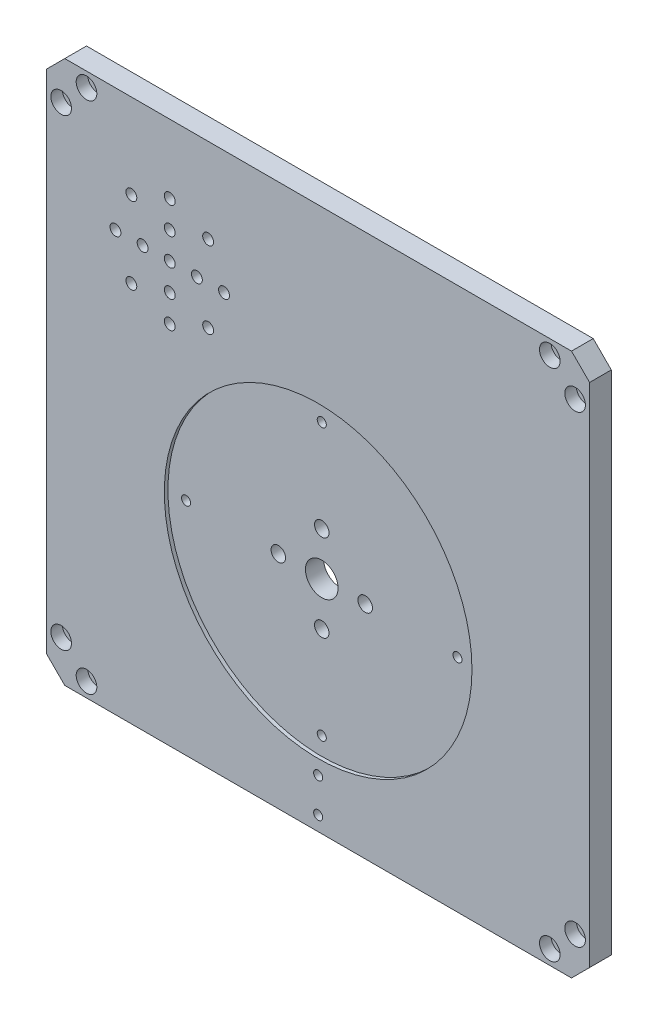
from build123d import *

# Parameters (mm, degrees)
SKETCH_1_W             = 150
SKETCH_1_H             = 150
EXTRUDE_1_DEPTH        = 6
SKETCH_2_R             = 42.5
CUT_EXTRUDE_1_DEPTH    = 1
CHAMFER_1_SIZE         = 5
SKETCH_4_R             = 1.5
CUT_EXTRUDE_3_DEPTH    = 10
SKETCH_5_R             = 2.85
CUT_EXTRUDE_4_DEPTH    = 3.2
SKETCH_6_R             = 1.5
CUT_EXTRUDE_5_DEPTH    = 10
SKETCH_7_R             = 2.85
CUT_EXTRUDE_6_DEPTH    = 3.2
SKETCH_8_R             = 4.5
CUT_EXTRUDE_7_DEPTH    = 10
SKETCH_9_R             = 2
CUT_EXTRUDE_8_DEPTH    = 10
SKETCH_10_R            = 1
CUT_EXTRUDE_9_DEPTH    = 10
HOLE_WIZARD_M3_1_D     = 2.5
HOLE_WIZARD_M3_1_DEPTH = 7.5
HOLE_WIZARD_M3_1_TIP   = 0.751075774
SKETCH_15_R            = 25.5
CUT_EXTRUDE_12_DEPTH   = 3
SKETCH_16_R            = 1.5
CUT_EXTRUDE_13_DEPTH   = 3
SKETCH_17_R            = 1
CUT_EXTRUDE_14_DEPTH   = 10
HOLE_WIZARD_M3_2_D     = 2.5
HOLE_WIZARD_M3_2_DEPTH = 7.5
HOLE_WIZARD_M3_2_TIP   = 0.751075774


with BuildPart() as part:
    # 草图1 → 凸台-拉伸1 (new body)
    with BuildSketch(Plane.XY):
        Rectangle(SKETCH_1_W, SKETCH_1_H)
    extrude(amount=EXTRUDE_1_DEPTH)

    # 草图2 → 切除-拉伸1 (cut)
    with BuildSketch(Plane.XY.offset(6)):
        with Locations((0, -15)):
            Circle(SKETCH_2_R)
    extrude(amount=-CUT_EXTRUDE_1_DEPTH, mode=Mode.SUBTRACT)

    # 倒角1
    chamfer_1_edges = [part.edges().sort_by_distance(p)[0] for p in [
        (-75, 75, 3),
        (75, 75, 3),
        (75, -75, 3),
        (-75, -75, 3),
    ]]
    chamfer(chamfer_1_edges, length=CHAMFER_1_SIZE)

    # 草图4 → 切除-拉伸3 (cut)
    with BuildSketch(Plane.XY.offset(6)):
        with Locations((64, 71)):
            Circle(SKETCH_4_R)
        with Locations((71, 64)):
            Circle(SKETCH_4_R)
    cut_extrude_3 = extrude(amount=-CUT_EXTRUDE_3_DEPTH, mode=Mode.SUBTRACT)

    # 草图5 → 切除-拉伸4 (cut)
    with BuildSketch(Plane.XY.offset(6)):
        with Locations((64, 71)):
            Circle(SKETCH_5_R)
        with Locations((71, 64)):
            Circle(SKETCH_5_R)
    cut_extrude_4 = extrude(amount=-CUT_EXTRUDE_4_DEPTH, mode=Mode.SUBTRACT)

    # 草图6 → 切除-拉伸5 (cut)
    with BuildSketch(Plane.XY.offset(6)):
        with Locations((-64, 71)):
            Circle(SKETCH_6_R)
        with Locations((-71, 64)):
            Circle(SKETCH_6_R)
    cut_extrude_5 = extrude(amount=-CUT_EXTRUDE_5_DEPTH, mode=Mode.SUBTRACT)

    # 草图7 → 切除-拉伸6 (cut)
    with BuildSketch(Plane.XY.offset(6)):
        with Locations((-64, 71)):
            Circle(SKETCH_7_R)
        with Locations((-71, 64)):
            Circle(SKETCH_7_R)
    cut_extrude_6 = extrude(amount=-CUT_EXTRUDE_6_DEPTH, mode=Mode.SUBTRACT)

    # 镜向1: 切除-拉伸3, 切除-拉伸4, 切除-拉伸5, 切除-拉伸6 across plane
    add(cut_extrude_3.mirror(Plane.ZX), mode=Mode.SUBTRACT)
    add(cut_extrude_4.mirror(Plane.ZX), mode=Mode.SUBTRACT)
    add(cut_extrude_5.mirror(Plane.ZX), mode=Mode.SUBTRACT)
    add(cut_extrude_6.mirror(Plane.ZX), mode=Mode.SUBTRACT)

    # 草图8 → 切除-拉伸7 (cut)
    with BuildSketch(Plane.XY.offset(5)):
        with Locations((0, -15)):
            Circle(SKETCH_8_R)
    extrude(amount=-CUT_EXTRUDE_7_DEPTH, mode=Mode.SUBTRACT)

    # 草图9 → 切除-拉伸8 (cut)
    with BuildSketch(Plane.XY.offset(5)):
        with Locations((-12, -15)):
            Circle(SKETCH_9_R)
        with Locations((12, -15)):
            Circle(SKETCH_9_R)
        with Locations((0, -27)):
            Circle(SKETCH_9_R)
        with Locations((0, -3)):
            Circle(SKETCH_9_R)
    extrude(amount=-CUT_EXTRUDE_8_DEPTH, mode=Mode.SUBTRACT)

    # 草图10 → 切除-拉伸9 (cut)
    with BuildSketch(Plane.XY.offset(5)):
        with Locations((0, 22.5)):
            Circle(SKETCH_10_R)
        with Locations((37.5, -15)):
            Circle(SKETCH_10_R)
        with Locations((0, -52.5)):
            Circle(SKETCH_10_R)
        with Locations((-37.5, -15)):
            Circle(SKETCH_10_R)
    extrude(amount=-CUT_EXTRUDE_9_DEPTH, mode=Mode.SUBTRACT)

    # M3 螺纹孔1
    with Locations(Plane.XY.offset(5)):
        with Locations((0, 22.5), (-37.5, -15), (0, -52.5), (37.5, -15)):
            Hole(HOLE_WIZARD_M3_1_D / 2, depth=HOLE_WIZARD_M3_1_DEPTH)
            with Locations((0, 0, -(HOLE_WIZARD_M3_1_DEPTH + HOLE_WIZARD_M3_1_TIP / 2))):  # 118° drill point
                Cone(0, HOLE_WIZARD_M3_1_D / 2, HOLE_WIZARD_M3_1_TIP, mode=Mode.SUBTRACT)

    # 草图15 → 切除-拉伸12 (cut)
    with BuildSketch(Plane(origin=(0, 0, 0), x_dir=(-1, 0, 0), z_dir=(0, 0, -1))):
        with Locations((41, 41)):
            Circle(SKETCH_15_R)
    extrude(amount=-CUT_EXTRUDE_12_DEPTH, mode=Mode.SUBTRACT)

    # 草图16 → 切除-拉伸13 (cut)
    with BuildSketch(Plane(origin=(0, 0, 3), x_dir=(-1, 0, 0), z_dir=(0, 0, -1))):
        with Locations((41, 41)):
            Circle(SKETCH_16_R)
        with Locations((41, 48.5)):
            Circle(SKETCH_16_R)
        with Locations((48.5, 41)):
            Circle(SKETCH_16_R)
        with Locations((41, 33.5)):
            Circle(SKETCH_16_R)
        with Locations((33.5, 41)):
            Circle(SKETCH_16_R)
        with Locations((41, 56)):
            Circle(SKETCH_16_R)
        with Locations((51.606601718, 51.606601718)):
            Circle(SKETCH_16_R)
        with Locations((56, 41)):
            Circle(SKETCH_16_R)
        with Locations((51.606601718, 30.393398282)):
            Circle(SKETCH_16_R)
        with Locations((41, 26)):
            Circle(SKETCH_16_R)
        with Locations((30.393398282, 30.393398282)):
            Circle(SKETCH_16_R)
        with Locations((26, 41)):
            Circle(SKETCH_16_R)
        with Locations((30.393398282, 51.606601718)):
            Circle(SKETCH_16_R)
    extrude(amount=-CUT_EXTRUDE_13_DEPTH, mode=Mode.SUBTRACT)

    # 草图17 → 切除-拉伸14 (cut)
    with BuildSketch(Plane.XY.offset(6)):
        with Locations((0, -61.5)):
            Circle(SKETCH_17_R)
        with Locations((0, -71)):
            Circle(SKETCH_17_R)
    extrude(amount=-CUT_EXTRUDE_14_DEPTH, mode=Mode.SUBTRACT)

    # M3 螺纹孔2
    with Locations(Plane.XY.offset(6)):
        with Locations((0, -61.5), (0, -71)):
            Hole(HOLE_WIZARD_M3_2_D / 2, depth=HOLE_WIZARD_M3_2_DEPTH)
            with Locations((0, 0, -(HOLE_WIZARD_M3_2_DEPTH + HOLE_WIZARD_M3_2_TIP / 2))):  # 118° drill point
                Cone(0, HOLE_WIZARD_M3_2_D / 2, HOLE_WIZARD_M3_2_TIP, mode=Mode.SUBTRACT)


solid = part.part
